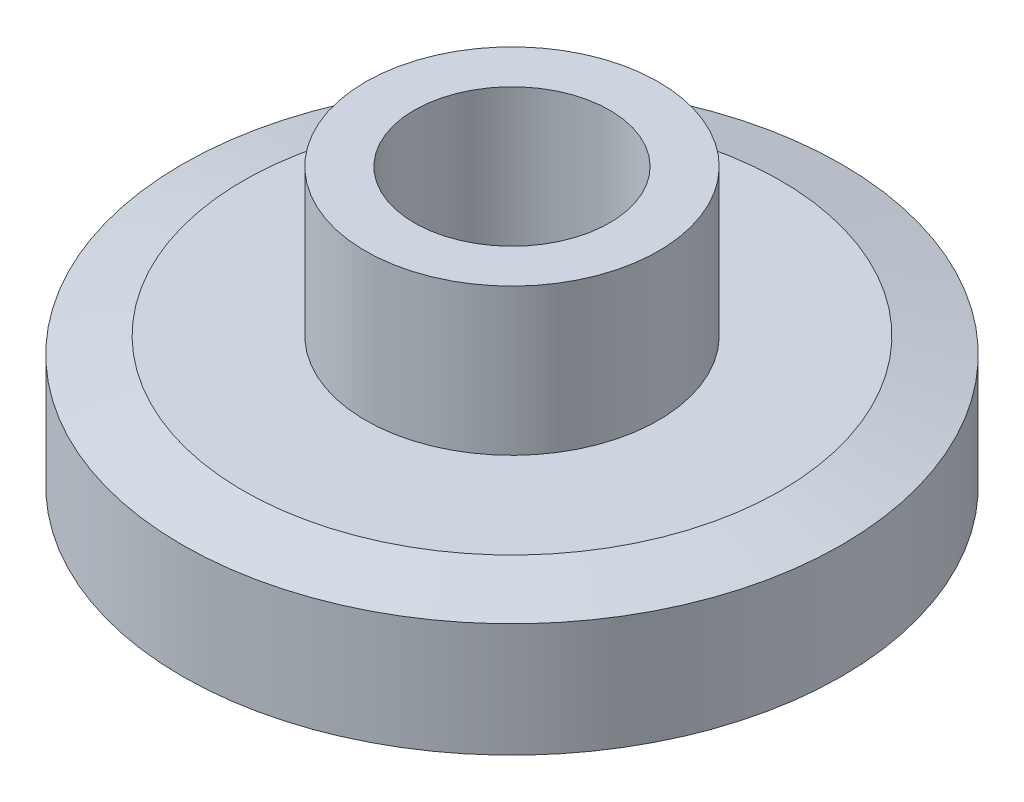
from build123d import *

# Parameters (mm, degrees)
CHAMFER_2_SIZE           = 1.25
CHAMFER_2_SIZE2          = 0.334936491
CHAMFER_3_SIZE           = 1.25
CHAMFER_3_SIZE2          = 0.334936491
SKETCH_4_R               = 2
CUT_EXTRUDE_2_DEPTH      = 1
CUT_EXTRUDE_2_DEPTH_BACK = 7


with BuildPart() as part:
    # Эскиз2 → Повернуть2 (revolve)
    with BuildSketch(Plane.XY):
        Polygon((0, 0), (6.75, 0), (6.75, 3), (3, 3), (3, 6), (0, 6), align=None)
    revolve(axis=Axis((0, 6, 0), (0, -1, 0)))

    # Фаска2
    chamfer_2_edges = [part.edges().sort_by_distance(p)[0] for p in [
        (-6.75, 3, 0),
    ]]
    chamfer_2_side = [part.faces().sort_by_distance(p)[0] for p in [
        (-6.559081169, 3, 0),
    ]]
    chamfer(chamfer_2_edges, length=CHAMFER_2_SIZE, length2=CHAMFER_2_SIZE2, reference=chamfer_2_side[0])

    # Фаска3
    chamfer_3_edges = [part.edges().sort_by_distance(p)[0] for p in [
        (-6.75, 0, 0),
    ]]
    chamfer_3_side = [part.faces().sort_by_distance(p)[0] for p in [
        (0, 0, 0),
    ]]
    chamfer(chamfer_3_edges, length=CHAMFER_3_SIZE, length2=CHAMFER_3_SIZE2, reference=chamfer_3_side[0])

    # Эскиз4 → Вырез-Вытянуть2 (cut, two sides)
    with BuildSketch(Plane(origin=(0, 6, 0), x_dir=(1, 0, 0), z_dir=(0, 1, 0))) as cut_extrude_2_sk:
        Circle(SKETCH_4_R)
    extrude(amount=CUT_EXTRUDE_2_DEPTH, mode=Mode.SUBTRACT)
    extrude(cut_extrude_2_sk.sketch, amount=-CUT_EXTRUDE_2_DEPTH_BACK, mode=Mode.SUBTRACT)


solid = part.part
